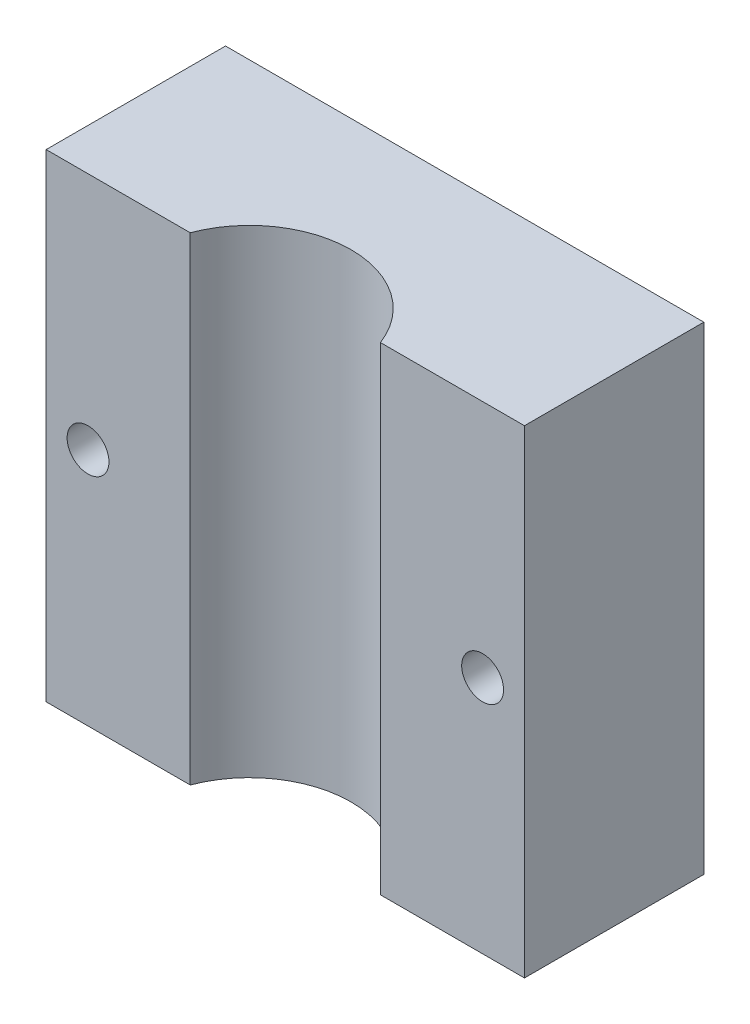
from build123d import *

# Parameters (mm, degrees)
SKETCH1_W           = 40
SKETCH1_H           = 40
BOSS_EXTRUDE1_DEPTH = 15
SKETCH2_R           = 1.75
CUT_EXTRUDE1_DEPTH  = 16
SKETCH3_R           = 8.5
CUT_EXTRUDE2_DEPTH  = 41


with BuildPart() as part:
    # Sketch1 → Boss-Extrude1 (new body)
    with BuildSketch(Plane.XY):
        Rectangle(SKETCH1_W, SKETCH1_H)
    extrude(amount=BOSS_EXTRUDE1_DEPTH)

    # Sketch2 → Cut-Extrude1 (cut, through all)
    with BuildSketch(Plane.XY.offset(15)):
        with Locations((-16.5, 0)):
            Circle(SKETCH2_R)
        with Locations((16.5, 0)):
            Circle(SKETCH2_R)
    extrude(amount=-CUT_EXTRUDE1_DEPTH, mode=Mode.SUBTRACT)

    # Sketch3 → Cut-Extrude2 (cut, through all)
    with BuildSketch(Plane(origin=(0, 20, 0), x_dir=(1, 0, 0), z_dir=(0, 1, 0))):
        with Locations((0, -18)):
            Circle(SKETCH3_R)
    extrude(amount=-CUT_EXTRUDE2_DEPTH, mode=Mode.SUBTRACT)


solid = part.part
